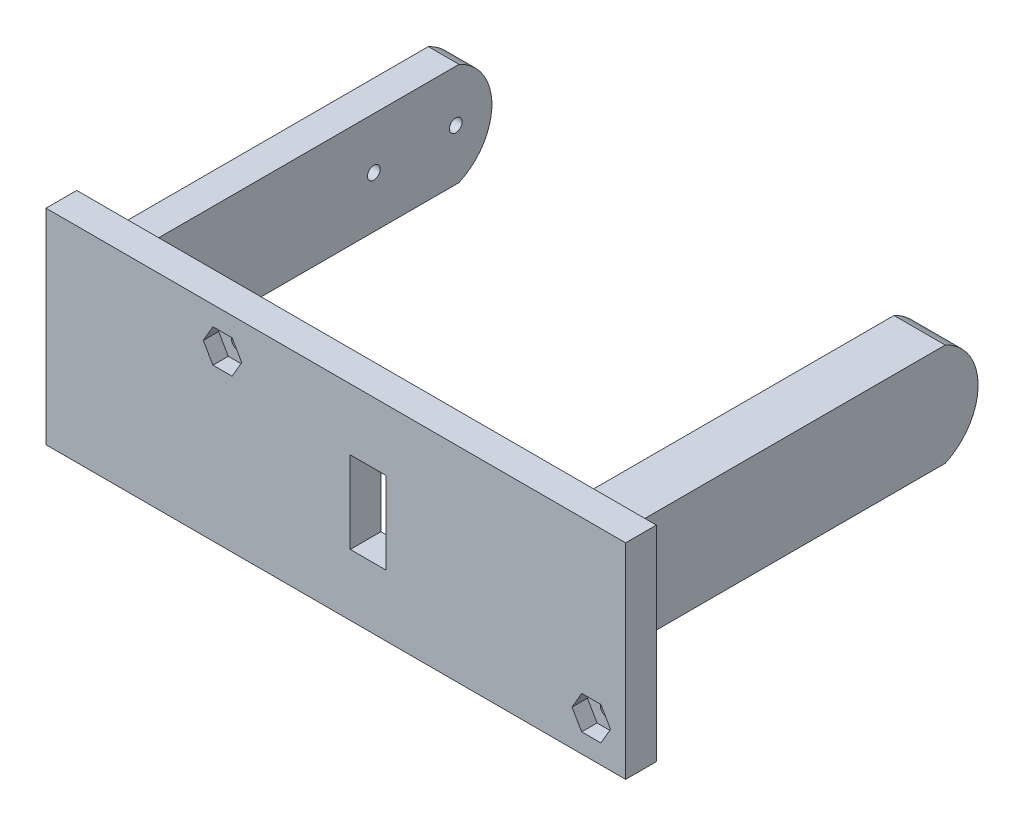
from build123d import *

# Parameters (mm, degrees)
BOSS_EXTRUDE1_DEPTH     = 25.4
SKETCH4_R               = 3.302
CUT_EXTRUDE2_DEPTH      = 7.62
SKETCH2_R               = 3.175
SKETCH2_R_2             = 1.5875
CUT_EXTRUDE3_DEPTH      = 7.62
SKETCH6_W               = 128.1684
SKETCH6_H               = 12.7
BOSS_EXTRUDE2_DEPTH     = 7.62
SKETCH9_W               = 15.550542335
SKETCH9_H               = 50.8
BOSS_EXTRUDE3_DEPTH     = 7.62
CUT_EXTRUDE4_DEPTH      = 3.81
SKETCH10_R              = 2.921
CUT_EXTRUDE5_DEPTH      = 3.048
SKETCH11_R              = 1.5875
CUT_EXTRUDE6_DEPTH      = 106.41
CUT_EXTRUDE7_REACH      = 111.22
SKETCH12_W              = 8.89
SKETCH12_H              = 20.32
SKETCH13_R              = 3.175
BOSS_EXTRUDE4_DEPTH     = 7.62
CUT_EXTRUDE8_DEPTH      = 1
CUT_EXTRUDE8_DEPTH_BACK = 144.718942335


with BuildPart() as part:
    # Sketch1 → Boss-Extrude1 (new body)
    with BuildSketch(Plane(origin=(0, 0, 0), x_dir=(1, 0, 0), z_dir=(0, 1, 0))):
        Polygon((0, 0), (0, -101.6), (107.8484, -101.6), (107.8484, 0), (120.5484, 0), (120.5484, -109.22), (-7.62, -109.22), (-7.62, 0), align=None)
    extrude(amount=BOSS_EXTRUDE1_DEPTH)

    # Sketch4 → Cut-Extrude2 (cut)
    with BuildSketch(Plane.ZY.offset(-107.8484)):
        with Locations((25.4, 12.7)):
            Circle(SKETCH4_R)
    extrude(amount=-CUT_EXTRUDE2_DEPTH, mode=Mode.SUBTRACT)

    # Sketch2 → Cut-Extrude3 (cut)
    with BuildSketch(Plane(origin=(0, 0, 0), x_dir=(0, 0, -1), z_dir=(1, 0, 0))):
        with Locations((-25.4, 12.7)):
            Circle(SKETCH2_R)
        with Locations((-15.24, 12.7)):
            Circle(SKETCH2_R_2)
        with Locations((-35.56, 12.7)):
            Circle(SKETCH2_R_2)
    extrude(amount=-CUT_EXTRUDE3_DEPTH, mode=Mode.SUBTRACT)

    # Sketch6 → Boss-Extrude2 (add)
    with BuildSketch(Plane.XY.offset(109.22)):
        with Locations((56.4642, 31.75)):
            Rectangle(SKETCH6_W, SKETCH6_H)
        with Locations((56.4642, -6.35)):
            Rectangle(SKETCH6_W, SKETCH6_H)
    extrude(amount=-BOSS_EXTRUDE2_DEPTH)

    # Sketch9 → Boss-Extrude3 (add)
    with BuildSketch(Plane.XY.offset(109.22)):
        with Locations((128.323671168, 12.7)):
            Rectangle(SKETCH9_W, SKETCH9_H)
    extrude(amount=-BOSS_EXTRUDE3_DEPTH)

    # Sketch7 → Cut-Extrude4 (cut)
    with BuildSketch(Plane.XY.offset(109.22)):
        Polygon((40.910226472, 29.21), (38.527213236, 33.3375), (33.761186764, 33.3375), (31.378173528, 29.21), (33.761186764, 25.0825), (38.527213236, 25.0825), align=None)
        Polygon((132.350226472, -3.81), (129.967213236, 0.3175), (125.201186764, 0.3175), (122.818173528, -3.81), (125.201186764, -7.9375), (129.967213236, -7.9375), align=None)
    extrude(amount=-CUT_EXTRUDE4_DEPTH, mode=Mode.SUBTRACT)

    # Sketch10 → Cut-Extrude5 (cut)
    with BuildSketch(Plane.ZY.offset(7.62)):
        with Locations((15.24, 12.7)):
            Circle(SKETCH10_R)
        with Locations((35.56, 12.7)):
            Circle(SKETCH10_R)
    extrude(amount=-CUT_EXTRUDE5_DEPTH, mode=Mode.SUBTRACT)

    # Sketch11 → Cut-Extrude6 (cut, through all)
    with BuildSketch(Plane.XY.offset(105.41)):
        with Locations((36.1442, 29.21)):
            Circle(SKETCH11_R)
        with Locations((127.5842, -3.81)):
            Circle(SKETCH11_R)
    extrude(amount=-CUT_EXTRUDE6_DEPTH, mode=Mode.SUBTRACT)

    # Sketch12 → Cut-Extrude7 (cut, up to next)
    with BuildSketch(Plane.XY.offset(109.22), mode=Mode.PRIVATE) as cut_extrude7_sk1:
        with Locations((72.263, 12.7)):
            Rectangle(SKETCH12_W, SKETCH12_H)
    cut_extrude7_tool1 = extrude(cut_extrude7_sk1.sketch, amount=-CUT_EXTRUDE7_REACH, mode=Mode.PRIVATE) & part.part
    add(cut_extrude7_tool1.solids().sort_by_distance((72.263, 12.7, 109.22))[0], mode=Mode.SUBTRACT)

    # Sketch13 → Boss-Extrude4 (add)
    with BuildSketch(Plane.ZY.offset(7.62)):
        with Locations((25.4, 12.7)):
            Circle(SKETCH13_R)
    extrude(amount=-BOSS_EXTRUDE4_DEPTH)

    # Sketch14 → Cut-Extrude8 (cut, two sides)
    with BuildSketch(Plane.ZY.offset(7.62)) as cut_extrude8_sk:
        with BuildLine():
            Line((14.426351463, 25.4), (0, 25.4))
            Line((0, 25.4), (0, 0))
            Line((0, 0), (14.426351463, 0))
            ThreePointArc((14.426351463, 0), (6.276222595, 12.7), (14.426351463, 25.4))
        make_face()
    extrude(amount=CUT_EXTRUDE8_DEPTH, mode=Mode.SUBTRACT)
    extrude(cut_extrude8_sk.sketch, amount=-CUT_EXTRUDE8_DEPTH_BACK, mode=Mode.SUBTRACT)


solid = part.part
